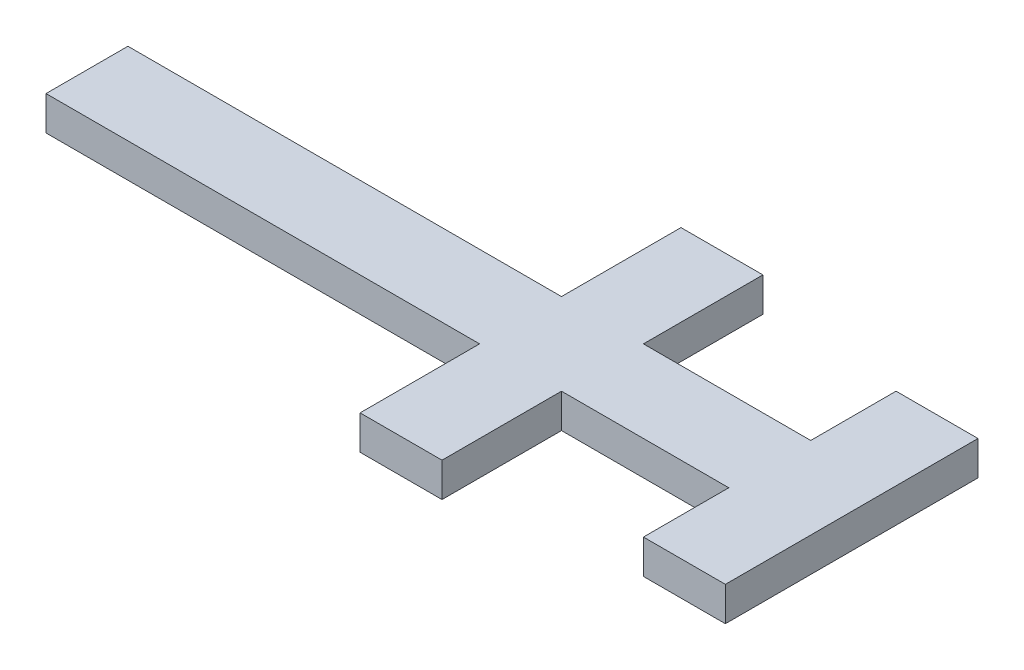
from build123d import *

# Parameters (mm, degrees)
SKETCH_3_W           = 10
SKETCH_3_H           = 35
SKETCH_3_W_2         = 26.5
SKETCH_3_H_2         = 10
SKETCH_3_W_3         = 38.5
SKETCH_3_W_4         = 25
EXTRUDE_1_DEPTH      = 1
EXTRUDE_2_DEPTH      = 4
EXTRUDE_2_DEPTH_BACK = 1
SKETCH_5_W           = 25
SKETCH_5_H           = 10
SKETCH_5_W_2         = 10
SKETCH_5_H_2         = 35
EXTRUDE_3_DEPTH      = 2


with BuildPart() as part:
    # 草图3 → 凸台-拉伸1 (new body)
    with BuildSketch(Plane(origin=(0, 0, 0), x_dir=(1, 0, 0), z_dir=(0, 1, 0))):
        with Locations((19, 0)):
            Rectangle(SKETCH_3_W, SKETCH_3_H)
        with Locations((0.75, 0)):
            Rectangle(SKETCH_3_W_2, SKETCH_3_H_2)
        Polygon((-12.5, -5), (-12.5, 5), (-12.5, 22.5), (-22.5, 22.5), (-22.5, 5), (-22.5, -5), (-22.5, -22.5), (-12.5, -22.5), align=None)
        with Locations((-41.75, 0)):
            Rectangle(SKETCH_3_W_3, SKETCH_3_H_2)
        with Locations((-73.5, 0)):
            Rectangle(SKETCH_3_W_4, SKETCH_3_H_2)
    extrude(amount=EXTRUDE_1_DEPTH)

    # 草图4 → 凸台-拉伸2 (add, two sides)
    with BuildSketch(Plane.XZ) as extrude_2_sk:
        Polygon((13, -18.5), (25, -18.5), (25, 18.5), (13, 18.5), (13, 6), (-11.5, 6), (-11.5, 23.5), (-23.5, 23.5), (-23.5, 6), (-87, 6), (-87, -6), (-23.5, -6), (-23.5, -23.5), (-11.5, -23.5), (-11.5, -6), (13, -6), align=None)
        Polygon((14, -17.5), (24, -17.5), (24, 17.5), (14, 17.5), (14, 5), (-12.5, 5), (-12.5, 22.5), (-22.5, 22.5), (-22.5, 5), (-86, 5), (-86, -5), (-22.5, -5), (-22.5, -22.5), (-12.5, -22.5), (-12.5, -5), (14, -5), align=None, mode=Mode.SUBTRACT)
    extrude(amount=EXTRUDE_2_DEPTH)
    extrude(extrude_2_sk.sketch, amount=-EXTRUDE_2_DEPTH_BACK)

    # 草图5 → 凸台-拉伸3 (add)
    with BuildSketch(Plane.XZ):
        Polygon((-22.5, 22.5), (-22.5, 5), (-21, 5), (-21, -5), (-22.5, -5), (-22.5, -22.5), (-12.5, -22.5), (-12.5, -5), (-14, -5), (-14, 5), (-12.5, 5), (-12.5, 22.5), align=None)
        with Locations((-73.5, 0)):
            Rectangle(SKETCH_5_W, SKETCH_5_H)
        with Locations((19, 0)):
            Rectangle(SKETCH_5_W_2, SKETCH_5_H_2)
    extrude(amount=EXTRUDE_3_DEPTH)


solid = part.part
